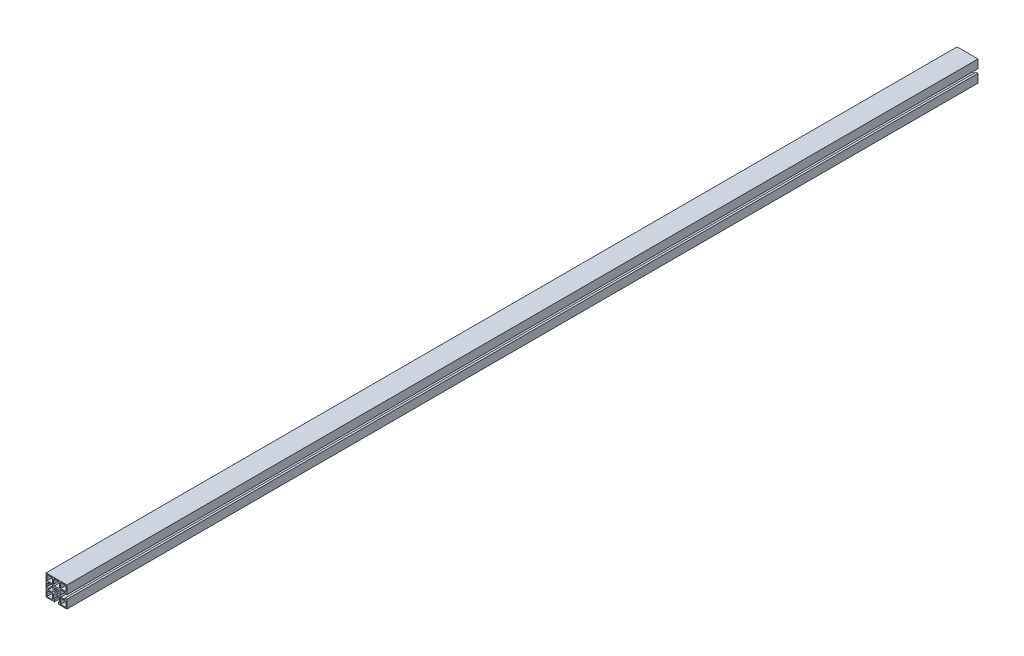
from build123d import *

# Parameters (mm, degrees)
SKETCH1_W           = 11.699975178
SKETCH1_H           = 11.699996949
SKETCH1_W_2         = 11.699990436
SKETCH1_H_2         = 11.699981689
SKETCH1_W_3         = 11.699990437
SKETCH1_H_3         = 11.699975177
SKETCH1_W_4         = 11.699981689
SKETCH1_H_4         = 11.699990436
BOSS_EXTRUDE1_DEPTH = 1955.8


with BuildPart() as part:
    # Sketch1 → Boss-Extrude1 (new body)
    with BuildSketch(Plane.XY):
        Polygon((22.500515052, 22.499297556), (-22.499484399, 22.499298105), (-22.499484948, -22.500701346), (-4.249491942, -22.500701568), (-4.249491942, -22.200733242), (-4.24949208, -18.000719999), (-6.799479919, -18.000719999), (-6.799480207, -9.200732353), (-4.799480391, -7.200732362), (4.800525817, -7.200732047), (6.8005258, -9.200731855), (6.800526088, -18.000720263), (4.250507877, -18.000720263), (4.250508015, -22.200733153), (4.250508015, -22.500701672), (22.500514502, -22.500701895), (22.500514725, -4.250714302), (22.200520351, -4.250714302), (18.000507108, -4.25071444), (18.000507108, -6.800702279), (9.200519462, -6.800702567), (7.200519471, -4.800702751), (7.200519156, 4.799303458), (9.200518964, 6.79930344), (18.000507424, 6.799303729), (18.000507424, 4.249285514), (22.200520261, 4.249285652), (22.500514829, 4.249285652), align=None)
        with BuildLine():
            Line((-4.249491247, 17.999291576), (-4.249490956, 22.199304807))
            Line((-4.249490956, 22.199304807), (-3.949472548, 22.199304807))
            Line((-3.949472548, 22.199304807), (-3.481695222, 21.73152644))
            ThreePointArc((-3.481695222, 21.73152644), (-2.670636178, 21.189593132), (-1.713926324, 20.999291428))
            Line((-1.713926324, 20.999291428), (1.714975167, 20.999291428))
            ThreePointArc((1.714975167, 20.999291428), (2.671722509, 21.189608628), (3.482801459, 21.731583767))
            Line((3.482801459, 21.731583767), (3.950490798, 22.199304487))
            Line((3.950490798, 22.199304487), (4.250509108, 22.199304487))
            Line((4.250509108, 22.199304487), (4.250508817, 17.999291575))
            Line((4.250508817, 17.999291575), (6.800527063, 17.999291575))
            Line((6.800527063, 17.999291575), (6.800526453, 9.199302988))
            Line((6.800526453, 9.199302988), (4.800526064, 7.199302969))
            Line((4.800526064, 7.199302969), (-4.799479817, 7.199303635))
            Line((-4.799479817, 7.199303635), (-6.799479854, 9.199304042))
            Line((-6.799479854, 9.199304042), (-6.799479244, 17.999291576))
            Line((-6.799479244, 17.999291576), (-4.249491247, 17.999291576))
        make_face(mode=Mode.SUBTRACT)
        with BuildLine():
            Line((-17.99949762, -4.250714253), (-22.199510799, -4.250714391))
            Line((-22.199510799, -4.250714391), (-22.199510799, -3.950696126))
            Line((-22.199510799, -3.950696126), (-21.731790056, -3.48300681))
            ThreePointArc((-21.731790056, -3.48300681), (-21.189814855, -2.671927844), (-20.999497617, -1.71518046))
            Line((-20.999497617, -1.71518046), (-20.999497617, 1.713721031))
            ThreePointArc((-20.999497617, 1.713721031), (-21.189799286, 2.670430863), (-21.731732544, 3.481489907))
            Line((-21.731732544, 3.481489907), (-22.199510888, 3.949267256))
            Line((-22.199510888, 3.949267256), (-22.199510888, 4.249285566))
            Line((-22.199510888, 4.249285566), (-17.999497356, 4.249285704))
            Line((-17.999497356, 4.249285704), (-17.999497356, 6.79927354))
            Line((-17.999497356, 6.79927354), (-9.199509947, 6.799273828))
            Line((-9.199509947, 6.799273828), (-7.199509956, 4.799274012))
            Line((-7.199509956, 4.799274012), (-7.199509641, -4.800732197))
            Line((-7.199509641, -4.800732197), (-9.199509449, -6.800732179))
            Line((-9.199509449, -6.800732179), (-17.99949762, -6.800732468))
            Line((-17.99949762, -6.800732468), (-17.99949762, -4.250714253))
        make_face(mode=Mode.SUBTRACT)
        with Locations((-14.649542346, -14.650709384)):
            Rectangle(SKETCH1_W, SKETCH1_H, mode=Mode.SUBTRACT)
        with Locations((14.65050626, -14.650767962)):
            Rectangle(SKETCH1_W_2, SKETCH1_H_2, mode=Mode.SUBTRACT)
        with BuildLine():
            Line((-3.181457266, -4.596908447), (-4.595670829, -3.182694885))
            Line((-4.595670829, -3.182694885), (-3.26221457, -1.849238626))
            ThreePointArc((-3.26221457, -1.849238626), (-3.749476751, -0.00071437), (-3.26221457, 1.847809887))
            Line((-3.26221457, 1.847809887), (-4.595670829, 3.181266146))
            Line((-4.595670829, 3.181266146), (-3.181457266, 4.595479708))
            Line((-3.181457266, 4.595479708), (-1.848001007, 3.262023449))
            ThreePointArc((-1.848001007, 3.262023449), (0.000523249, 3.74928563), (1.849047505, 3.262023449))
            Line((1.849047505, 3.262023449), (3.182503764, 4.595479708))
            Line((3.182503764, 4.595479708), (4.596717327, 3.181266146))
            Line((4.596717327, 3.181266146), (3.263261068, 1.847809887))
            ThreePointArc((3.263261068, 1.847809887), (3.750523249, -0.00071437), (3.263261068, -1.849238626))
            Line((3.263261068, -1.849238626), (4.596717327, -3.182694885))
            Line((4.596717327, -3.182694885), (3.182503764, -4.596908447))
            Line((3.182503764, -4.596908447), (1.849047505, -3.263452188))
            ThreePointArc((1.849047505, -3.263452188), (0.000523249, -3.75071437), (-1.848001007, -3.263452188))
            Line((-1.848001007, -3.263452188), (-3.181457266, -4.596908447))
        make_face(mode=Mode.SUBTRACT)
        with Locations((-14.64949028, 14.649335967)):
            Rectangle(SKETCH1_W_3, SKETCH1_H_3, mode=Mode.SUBTRACT)
        with Locations((14.650561583, 14.6492839)):
            Rectangle(SKETCH1_W_4, SKETCH1_H_4, mode=Mode.SUBTRACT)
    extrude(amount=BOSS_EXTRUDE1_DEPTH)


solid = part.part
